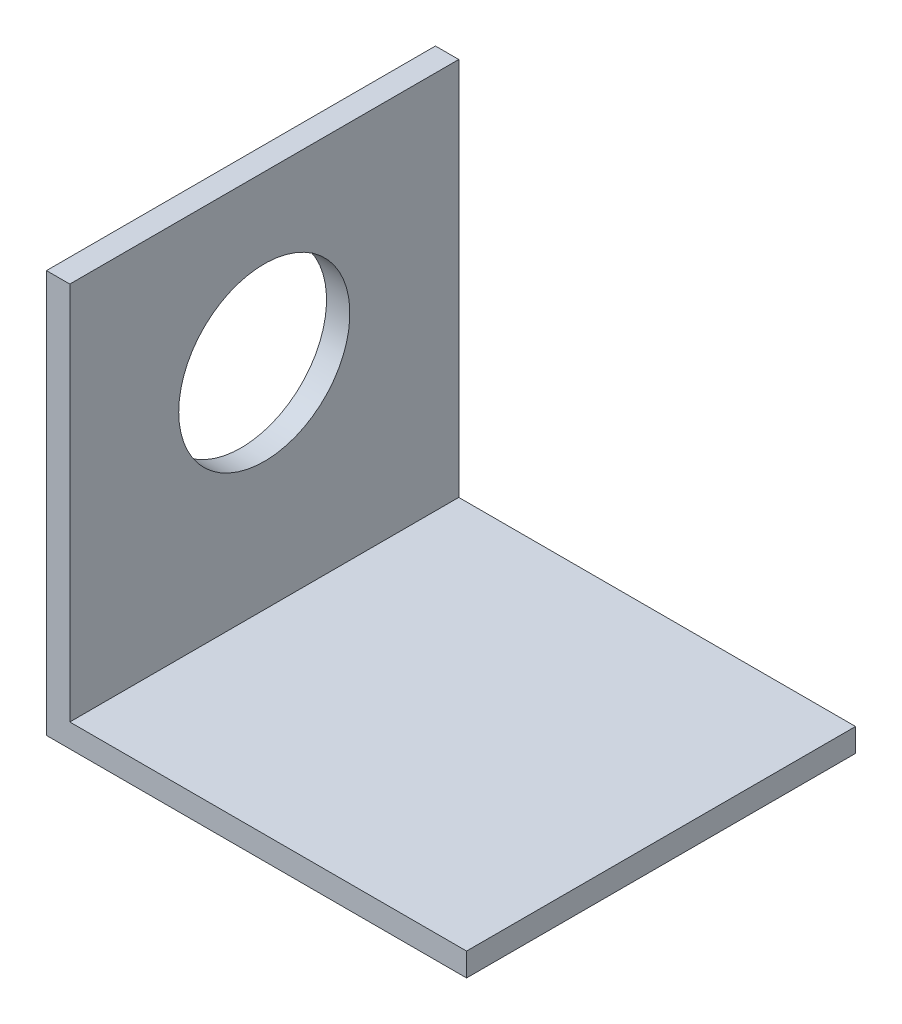
from build123d import *

# Parameters (mm, degrees)
SKETCH1_W           = 54
SKETCH1_H           = 50
BOSS_EXTRUDE1_DEPTH = 3
SKETCH2_W           = 3
SKETCH2_H           = 50
BOSS_EXTRUDE2_DEPTH = 48.75
SKETCH3_R           = 11
CUT_EXTRUDE1_DEPTH  = 55


with BuildPart() as part:
    # Sketch1 → Boss-Extrude1 (new body)
    with BuildSketch(Plane(origin=(0, 0, 0), x_dir=(1, 0, 0), z_dir=(0, 1, 0))):
        Rectangle(SKETCH1_W, SKETCH1_H)
    extrude(amount=BOSS_EXTRUDE1_DEPTH)

    # Sketch2 → Boss-Extrude2 (add)
    with BuildSketch(Plane(origin=(0, 3, 0), x_dir=(1, 0, 0), z_dir=(0, 1, 0))):
        with Locations((-25.5, 0)):
            Rectangle(SKETCH2_W, SKETCH2_H)
    extrude(amount=BOSS_EXTRUDE2_DEPTH)

    # Sketch3 → Cut-Extrude1 (cut, through all)
    with BuildSketch(Plane.ZY.offset(27)):
        with Locations((0, 30.5)):
            Circle(SKETCH3_R)
    extrude(amount=-CUT_EXTRUDE1_DEPTH, mode=Mode.SUBTRACT)


solid = part.part
